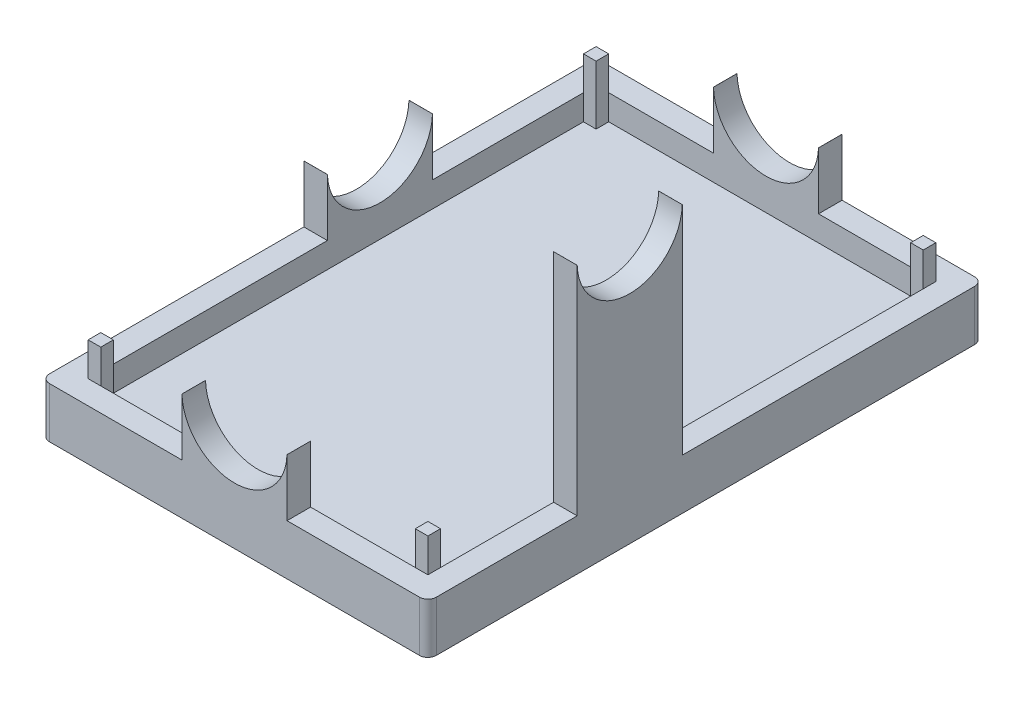
from build123d import *

# Parameters (mm, degrees)
SKETCH1_W           = 46
SKETCH1_H           = 66
BOSS_EXTRUDE1_DEPTH = 3
SKETCH2_W           = 46
SKETCH2_H           = 66
SKETCH2_W_2         = 40
SKETCH2_H_2         = 60
BOSS_EXTRUDE2_DEPTH = 3
SKETCH3_W           = 60
SKETCH3_H           = 3
CUT_EXTRUDE1_DEPTH  = 0.2
SKETCH4_W           = 40.2
SKETCH4_H           = 3
CUT_EXTRUDE2_DEPTH  = 0.2
SKETCH5_W           = 60.2
SKETCH5_H           = 3
CUT_EXTRUDE3_DEPTH  = 0.2
SKETCH6_W           = 40.4
SKETCH6_H           = 3
CUT_EXTRUDE4_DEPTH  = 0.2
BOSS_EXTRUDE3_DEPTH = 6.8
BOSS_EXTRUDE4_DEPTH = 6.8
SKETCH11_R          = 6.25
CUT_EXTRUDE5_DEPTH  = 66
BOSS_EXTRUDE5_DEPTH = 6.8
SKETCH13_R          = 6.25
CUT_EXTRUDE6_DEPTH  = 3
SKETCH14_W          = 2.8
SKETCH14_H          = 12.5
BOSS_EXTRUDE6_DEPTH = 25.8
SKETCH15_R          = 6.25
CUT_EXTRUDE7_DEPTH  = 4.8
SKETCH16_W          = 1.5
SKETCH16_H          = 1.5
BOSS_EXTRUDE7_DEPTH = 7
FILLET1_R           = 1
CUT_EXTRUDE8_DEPTH  = 0.2


with BuildPart() as part:
    # Sketch1 → Boss-Extrude1 (new body)
    with BuildSketch(Plane(origin=(0, 0, 0), x_dir=(1, 0, 0), z_dir=(0, 1, 0))):
        with Locations((27.944017639, 37.293489003)):
            Rectangle(SKETCH1_W, SKETCH1_H)
    extrude(amount=BOSS_EXTRUDE1_DEPTH)

    # Sketch2 → Boss-Extrude2 (add)
    with BuildSketch(Plane(origin=(0, 3, 0), x_dir=(1, 0, 0), z_dir=(0, 1, 0))):
        with Locations((27.944017639, 37.293489003)):
            Rectangle(SKETCH2_W, SKETCH2_H)
        with Locations((27.944017639, 37.293489003)):
            Rectangle(SKETCH2_W_2, SKETCH2_H_2, mode=Mode.SUBTRACT)
    extrude(amount=BOSS_EXTRUDE2_DEPTH)

    # Sketch3 → Cut-Extrude1 (cut)
    with BuildSketch(Plane(origin=(7.944017639, 0, 0), x_dir=(0, 0, -1), z_dir=(1, 0, 0))):
        with Locations((37.293489003, 4.5)):
            Rectangle(SKETCH3_W, SKETCH3_H)
    extrude(amount=-CUT_EXTRUDE1_DEPTH, mode=Mode.SUBTRACT)

    # Sketch4 → Cut-Extrude2 (cut)
    with BuildSketch(Plane(origin=(0, 0, -7.293489003), x_dir=(-1, 0, 0), z_dir=(0, 0, -1))):
        with Locations((-27.844017639, 4.5)):
            Rectangle(SKETCH4_W, SKETCH4_H)
    extrude(amount=-CUT_EXTRUDE2_DEPTH, mode=Mode.SUBTRACT)

    # Sketch5 → Cut-Extrude3 (cut)
    with BuildSketch(Plane.ZY.offset(-47.944017639)):
        with Locations((-37.193489003, 4.5)):
            Rectangle(SKETCH5_W, SKETCH5_H)
    extrude(amount=-CUT_EXTRUDE3_DEPTH, mode=Mode.SUBTRACT)

    # Sketch6 → Cut-Extrude4 (cut)
    with BuildSketch(Plane.XY.offset(-67.293489003)):
        with Locations((27.944017639, 4.5)):
            Rectangle(SKETCH6_W, SKETCH6_H)
    extrude(amount=-CUT_EXTRUDE4_DEPTH, mode=Mode.SUBTRACT)

    # Sketch8 → Boss-Extrude3 (add)
    with BuildSketch(Plane(origin=(0, 6, 0), x_dir=(1, 0, 0), z_dir=(0, 1, 0))):
        Polygon((27.944017639, 7.093489003), (34.194017639, 7.093489003), (34.194017639, 4.293489003), (21.694017639, 4.293489003), (21.694017639, 7.093489003), align=None)
    extrude(amount=BOSS_EXTRUDE3_DEPTH)

    # Sketch10 → Boss-Extrude4 (add)
    with BuildSketch(Plane(origin=(0, 6, 0), x_dir=(1, 0, 0), z_dir=(0, 1, 0))):
        Polygon((27.944017639, 67.493489003), (34.194017639, 67.493489003), (34.194017639, 70.293489003), (21.694017639, 70.293489003), (21.694017639, 67.493489003), align=None)
    extrude(amount=BOSS_EXTRUDE4_DEPTH)

    # Sketch11 → Cut-Extrude5 (cut)
    with BuildSketch(Plane.XY.offset(-4.293489003)):
        with Locations((27.944017639, 13)):
            Circle(SKETCH11_R)
    extrude(amount=-CUT_EXTRUDE5_DEPTH, mode=Mode.SUBTRACT)

    # Sketch12 → Boss-Extrude5 (add)
    with BuildSketch(Plane(origin=(0, 6, 0), x_dir=(1, 0, 0), z_dir=(0, 1, 0))):
        Polygon((7.744017639, 48.043489003), (4.944017639, 48.043489003), (4.944017639, 35.543489003), (7.744017639, 35.543489003), (7.744017639, 41.793489003), align=None)
    extrude(amount=BOSS_EXTRUDE5_DEPTH)

    # Sketch13 → Cut-Extrude6 (cut)
    with BuildSketch(Plane.ZY.offset(-4.944017639)):
        with Locations((-41.793489003, 13)):
            Circle(SKETCH13_R)
    extrude(amount=-CUT_EXTRUDE6_DEPTH, mode=Mode.SUBTRACT)

    # Sketch14 → Boss-Extrude6 (add)
    with BuildSketch(Plane(origin=(0, 6, 0), x_dir=(1, 0, 0), z_dir=(0, 1, 0))):
        with Locations((49.544017639, 28.293489003)):
            Rectangle(SKETCH14_W, SKETCH14_H)
    extrude(amount=BOSS_EXTRUDE6_DEPTH)

    # Sketch15 → Cut-Extrude7 (cut)
    with BuildSketch(Plane(origin=(50.944017639, 0, 0), x_dir=(0, 0, -1), z_dir=(1, 0, 0))):
        with Locations((28.293489003, 32)):
            Circle(SKETCH15_R)
    extrude(amount=-CUT_EXTRUDE7_DEPTH, mode=Mode.SUBTRACT)

    # Sketch16 → Boss-Extrude7 (add)
    with BuildSketch(Plane(origin=(0, 3, 0), x_dir=(1, 0, 0), z_dir=(0, 1, 0))):
        with Locations((8.494017639, 66.743489003)):
            Rectangle(SKETCH16_W, SKETCH16_H)
        with Locations((47.394017639, 66.743489003)):
            Rectangle(SKETCH16_W, SKETCH16_H)
        with Locations((47.394017639, 7.843489003)):
            Rectangle(SKETCH16_W, SKETCH16_H)
        with Locations((8.494017639, 7.843489003)):
            Rectangle(SKETCH16_W, SKETCH16_H)
    extrude(amount=BOSS_EXTRUDE7_DEPTH)

    # Fillet1
    fillet1_edges = [part.edges().sort_by_distance(p)[0] for p in [
        (4.944017639, 3, -4.293489003),
        (4.944017639, 3, -70.293489003),
        (50.944017639, 3, -70.293489003),
        (50.944017639, 3, -4.293489003),
    ]]
    fillet(fillet1_edges, radius=FILLET1_R)

    # Sketch17 → Cut-Extrude8 (cut)
    with BuildSketch(Plane.XZ):
        with BuildLine():
            Line((7.701195945, -7.422366579), (7.416260048, -7.422366579))
            add(Edge.make_bspline(
                [(7.416260048, -7.422366579), (7.419034677, -7.383077045), (7.424457453, -7.306289002), (7.442761371, -7.194981848), (7.466857748, -7.090008017), (7.500409578, -6.992544812), (7.540061397, -6.901315524), (7.589080984, -6.817817839), (7.644287116, -6.740222259), (7.707478986, -6.67028854), (7.776823348, -6.607925546), (7.851604145, -6.55348765), (7.931440576, -6.507658598), (8.01615079, -6.469639557), (8.106005461, -6.440672533), (8.200494018, -6.419499916), (8.300015054, -6.40747827), (8.367922694, -6.405666733), (8.402723389, -6.404738373)],
                knots=[0, 0, 0, 0, 0.000118102, 0.000230821, 0.000338037, 0.000440814, 0.000539618, 0.000635943, 0.000730729, 0.000824853, 0.000918079, 0.001010058, 0.001101805, 0.001193764, 0.001288095, 0.001384537, 0.001483857, 0.001588259, 0.001588259, 0.001588259, 0.001588259], degree=3))
            add(Edge.make_bspline(
                [(8.402723389, -6.404738373), (8.432217299, -6.405535017), (8.490345422, -6.407105084), (8.575705535, -6.417598326), (8.65705849, -6.437289), (8.73492156, -6.462835101), (8.808495833, -6.49731523), (8.879130104, -6.537777123), (8.945117015, -6.587311256), (9.007253139, -6.642883778), (9.063436321, -6.704093768), (9.112539208, -6.769437735), (9.155461258, -6.83764641), (9.188583072, -6.910708574), (9.215971134, -6.986455297), (9.233919047, -7.066179452), (9.245967298, -7.149146601), (9.247308133, -7.205863872), (9.247990817, -7.234741378)],
                knots=[0, 0, 0, 0, 8.8489e-05, 0.000174398, 0.000257396, 0.000339254, 0.00041979, 0.000500732, 0.000583034, 0.000666805, 0.000750533, 0.000831816, 0.000911775, 0.000991734, 0.001071996, 0.00115299, 0.001236461, 0.001323044, 0.001323044, 0.001323044, 0.001323044], degree=3))
            add(Edge.make_bspline(
                [(9.247990817, -7.234741378), (9.246566417, -7.275772035), (9.243701708, -7.358291646), (9.218768832, -7.481267417), (9.179708866, -7.603516288), (9.133872645, -7.705762826), (9.083725636, -7.791758647), (9.033319874, -7.86708166), (8.970049243, -7.952207882), (8.893758432, -8.04698303), (8.805433211, -8.152455781), (8.704315944, -8.268051488), (8.590222285, -8.39336902), (8.509273292, -8.479542277), (8.46696117, -8.524585128)],
                knots=[0, 0, 0, 0, 0.000122988, 0.000247351, 0.000374875, 0.000507521, 0.000582466, 0.000673312, 0.000779275, 0.000900556, 0.001038261, 0.001191968, 0.001361261, 0.001546658, 0.001546658, 0.001546658, 0.001546658], degree=3))
            Line((8.46696117, -8.524585128), (7.684023469, -9.376212732))
            Line((7.684023469, -9.376212732), (9.085170304, -9.376212732))
            Line((9.085170304, -9.376212732), (9.0489173, -9.66114863))
            Line((9.0489173, -9.66114863), (7.049913894, -9.66114863))
            Line((7.049913894, -9.66114863), (8.113971386, -8.504232564))
            add(Edge.make_bspline(
                [(8.113971386, -8.504232564), (8.138795432, -8.477113353), (8.187230161, -8.424200478), (8.257739029, -8.346526365), (8.324839919, -8.27300936), (8.386896429, -8.202001127), (8.446115539, -8.135468803), (8.501599693, -8.072420652), (8.552987828, -8.012911133), (8.600239669, -7.956524636), (8.643936381, -7.903967516), (8.68411955, -7.85524987), (8.719803985, -7.809593952), (8.752276538, -7.768168395), (8.780282375, -7.729489812), (8.805212384, -7.695084219), (8.825432982, -7.663533689), (8.858533166, -7.611717812), (8.896348205, -7.535227), (8.934983702, -7.433625775), (8.958210789, -7.332456636), (8.961461954, -7.26516704), (8.96305492, -7.232197308)],
                knots=[0, 0, 0, 0, 0.000110295, 0.0002152, 0.000314714, 0.000408889, 0.0004981, 0.000581924, 0.000660844, 0.000733972, 0.000802621, 0.000865897, 0.00092341, 0.00097646, 0.001023782, 0.001066665, 0.001103887, 0.00113618, 0.001251095, 0.00135896, 0.001461887, 0.001560765, 0.001560765, 0.001560765, 0.001560765], degree=3))
            add(Edge.make_bspline(
                [(8.96305492, -7.232197308), (8.962575453, -7.213516243), (8.961634143, -7.176840793), (8.953913828, -7.122841286), (8.940498496, -7.071286866), (8.92188294, -7.021849715), (8.898143989, -6.974591647), (8.869577616, -6.929101673), (8.834905225, -6.88650684), (8.795544901, -6.846662619), (8.75255776, -6.81009226), (8.706872832, -6.777051851), (8.657329765, -6.75068476), (8.605798295, -6.728045693), (8.551125902, -6.711049698), (8.493991951, -6.698027352), (8.433626184, -6.691273998), (8.392561426, -6.690215598), (8.371558526, -6.689674271)],
                knots=[0, 0, 0, 0, 5.6027e-05, 0.000109995, 0.000163216, 0.000215547, 0.000268168, 0.000321631, 0.000376362, 0.00043258, 0.000489425, 0.000545542, 0.000601327, 0.000657449, 0.000714172, 0.00077281, 0.000833003, 0.000896021, 0.000896021, 0.000896021, 0.000896021], degree=3))
            add(Edge.make_bspline(
                [(8.371558526, -6.689674271), (8.348206108, -6.690290482), (8.30259887, -6.691493942), (8.235767363, -6.700773218), (8.171948622, -6.715101293), (8.111096175, -6.736148384), (8.053888929, -6.763891968), (7.999159077, -6.79627855), (7.948065765, -6.835467475), (7.900618921, -6.880509602), (7.857111509, -6.93084104), (7.819034171, -6.986453828), (7.785534245, -7.046813598), (7.757728935, -7.112274814), (7.735488391, -7.182835695), (7.718503545, -7.258154393), (7.706083985, -7.33847721), (7.702853868, -7.393913031), (7.701195945, -7.422366579)],
                knots=[0, 0, 0, 0, 7.0034e-05, 0.000136777, 0.000202039, 0.000266002, 0.000329442, 0.000392488, 0.000456473, 0.000522159, 0.000588454, 0.000655671, 0.000723994, 0.000795231, 0.000868649, 0.000945639, 0.001026683, 0.001112147, 0.001112147, 0.001112147, 0.001112147], degree=3))
        make_face()
        Polygon((10.140959567, -6.48614863), (10.427803518, -6.48614863), (10.245266458, -7.788712732), (11.910360609, -7.788712732), (12.092897668, -6.48614863), (12.379741619, -6.48614863), (11.934529279, -9.66114863), (11.647685328, -9.66114863), (11.870291498, -8.07364863), (10.205197348, -8.07364863), (9.982591178, -9.66114863), (9.695747228, -9.66114863), align=None)
        Polygon((13.969785689, -6.48614863), (15.842221586, -6.48614863), (15.801516458, -6.771084527), (15.025574952, -6.771084527), (14.622975793, -9.66114863), (14.336131843, -9.66114863), (14.738731002, -6.771084527), (13.929080561, -6.771084527), align=None)
        Polygon((17.511131843, -6.404738373), (16.143057925, -10.10890504), (15.842221586, -10.10890504), (17.210295505, -6.404738373), align=None)
        with BuildLine():
            Line((18.24128008, -6.48614863), (19.027397869, -6.48614863))
            add(Edge.make_bspline(
                [(19.027397869, -6.48614863), (19.061112566, -6.4863509), (19.126232793, -6.486741586), (19.219947055, -6.490879428), (19.306371647, -6.495949194), (19.384998478, -6.505260745), (19.456705596, -6.515433351), (19.520533841, -6.529549014), (19.577230613, -6.545157131), (19.642209667, -6.56966321), (19.715313779, -6.60784007), (19.793896134, -6.665914392), (19.863669529, -6.735893476), (19.923749499, -6.816769877), (19.973964699, -6.906364305), (20.009494771, -7.004490092), (20.0311297, -7.109773411), (20.033588082, -7.182269809), (20.034849792, -7.219476955)],
                knots=[0, 0, 0, 0, 0.000101135, 0.000195343, 0.000281396, 0.000360763, 0.000432813, 0.000498557, 0.000556741, 0.000609073, 0.000706649, 0.000803072, 0.000901114, 0.001001987, 0.001104472, 0.001208096, 0.00131387, 0.001425393, 0.001425393, 0.001425393, 0.001425393], degree=3))
            add(Edge.make_bspline(
                [(20.034849792, -7.219476955), (20.033413752, -7.260544968), (20.030563738, -7.342049996), (20.002931273, -7.461462371), (19.960239208, -7.576566351), (19.900338278, -7.685354314), (19.826516808, -7.78567787), (19.738820416, -7.873879323), (19.638853413, -7.949190663), (19.545060683, -7.998890583), (19.464274136, -8.033086626), (19.397803593, -8.053983449), (19.327416681, -8.073760096), (19.251724022, -8.087584111), (19.171853488, -8.100129923), (19.087092858, -8.107938549), (18.997995963, -8.113206933), (18.937091721, -8.113965495), (18.905918502, -8.114353758)],
                knots=[0, 0, 0, 0, 0.00012303, 0.000244169, 0.00036573, 0.000490396, 0.000615439, 0.000738217, 0.00086224, 0.000989445, 0.001055591, 0.001125182, 0.001198313, 0.001274776, 0.00135582, 0.001440813, 0.001530001, 0.001623515, 0.001623515, 0.001623515, 0.001623515], degree=3))
            Line((18.905918502, -8.114353758), (19.912734407, -9.66114863))
            Line((19.912734407, -9.66114863), (19.587093381, -9.66114863))
            Line((19.587093381, -9.66114863), (18.580277476, -8.114353758))
            Line((18.580277476, -8.114353758), (18.299793702, -8.114353758))
            Line((18.299793702, -8.114353758), (18.082911691, -9.66114863))
            Line((18.082911691, -9.66114863), (17.79606774, -9.66114863))
            Line((17.79606774, -9.66114863), (18.24128008, -6.48614863))
        make_face()
        with BuildLine():
            Line((18.48805492, -6.771084527), (18.339862812, -7.829417861))
            Line((18.339862812, -7.829417861), (18.717657284, -7.829417861))
            add(Edge.make_bspline(
                [(18.717657284, -7.829417861), (18.751154509, -7.829245458), (18.815183183, -7.828915916), (18.906568812, -7.82782596), (18.988851324, -7.82542151), (19.061979555, -7.821409674), (19.126292158, -7.817392704), (19.181387987, -7.811468066), (19.227593654, -7.805761374), (19.254911516, -7.799701628), (19.267176514, -7.796980962)],
                knots=[0, 0, 0, 0, 0.000100493, 0.000192088, 0.000274174, 0.000347415, 0.000411807, 0.000467436, 0.000513669, 0.000551339, 0.000551339, 0.000551339, 0.000551339], degree=3))
            add(Edge.make_bspline(
                [(19.267176514, -7.796980962), (19.301927816, -7.787507292), (19.369956218, -7.768961841), (19.463231092, -7.722590757), (19.547116979, -7.665603761), (19.607130755, -7.606975865), (19.648630163, -7.554795696), (19.675396259, -7.513099296), (19.698550034, -7.469560574), (19.71763058, -7.423825703), (19.732359229, -7.37589718), (19.742328097, -7.325804315), (19.749034283, -7.273720736), (19.749617853, -7.238155142), (19.749913894, -7.220112973)],
                knots=[0, 0, 0, 0, 0.000107831, 0.000211087, 0.000310766, 0.000411065, 0.000461326, 0.000510547, 0.000559483, 0.000609093, 0.000658987, 0.000709629, 0.000762169, 0.000816264, 0.000816264, 0.000816264, 0.000816264], degree=3))
            add(Edge.make_bspline(
                [(19.749913894, -7.220112973), (19.749213027, -7.200161671), (19.747849846, -7.161356502), (19.739908979, -7.105081757), (19.725137899, -7.053187928), (19.704791958, -7.005596599), (19.678280962, -6.962450712), (19.646334464, -6.923372885), (19.608338828, -6.888528133), (19.579526225, -6.869297801), (19.564832764, -6.859490978)],
                knots=[0, 0, 0, 0, 5.987e-05, 0.000116447, 0.000170001, 0.000221279, 0.000271237, 0.000321402, 0.000372272, 0.00042521, 0.00042521, 0.00042521, 0.00042521], degree=3))
            add(Edge.make_bspline(
                [(19.564832764, -6.859490978), (19.551858137, -6.852136558), (19.524440206, -6.836595227), (19.477271572, -6.819530035), (19.423800206, -6.80408803), (19.362868124, -6.792401612), (19.294931083, -6.782980358), (19.219794005, -6.776205919), (19.137699395, -6.771553924), (19.080618539, -6.771245132), (19.050930521, -6.771084527)],
                knots=[0, 0, 0, 0, 4.4671e-05, 9.4398e-05, 0.000149962, 0.00021158, 0.000280299, 0.000355675, 0.000437842, 0.000526893, 0.000526893, 0.000526893, 0.000526893], degree=3))
            Line((19.050930521, -6.771084527), (18.48805492, -6.771084527))
        make_face(mode=Mode.SUBTRACT)
        with BuildLine():
            Line((23.535490817, -7.103085729), (23.23719855, -7.178135809))
            add(Edge.make_bspline(
                [(23.23719855, -7.178135809), (23.225673366, -7.142131514), (23.20326407, -7.072125614), (23.154186815, -6.976175074), (23.095590465, -6.891312755), (23.025923088, -6.820688273), (22.951329698, -6.762356021), (22.871376551, -6.720767149), (22.788332041, -6.694442005), (22.731326321, -6.691259038), (22.702943742, -6.689674271)],
                knots=[0, 0, 0, 0, 0.000113249, 0.000220198, 0.00032201, 0.000421411, 0.00051669, 0.000604877, 0.000690591, 0.000775584, 0.000775584, 0.000775584, 0.000775584], degree=3))
            add(Edge.make_bspline(
                [(22.702943742, -6.689674271), (22.672470475, -6.69100545), (22.613761392, -6.693570069), (22.5299708, -6.717207117), (22.455650296, -6.756778381), (22.39095532, -6.810532082), (22.338148867, -6.877316304), (22.300256495, -6.955860371), (22.277676273, -7.044816475), (22.27501628, -7.10740141), (22.273631843, -7.139974752)],
                knots=[0, 0, 0, 0, 9.127e-05, 0.000175839, 0.000258634, 0.000342185, 0.000426418, 0.000512038, 0.00060197, 0.00069958, 0.00069958, 0.00069958, 0.00069958], degree=3))
            add(Edge.make_bspline(
                [(22.273631843, -7.139974752), (22.275034391, -7.170671796), (22.277901268, -7.233418058), (22.304514579, -7.327377916), (22.343619272, -7.423709805), (22.380837046, -7.485162723), (22.400199351, -7.517133205)],
                knots=[0, 0, 0, 0, 9.1904e-05, 0.000187856, 0.000291087, 0.00040303, 0.00040303, 0.00040303, 0.00040303], degree=3))
            add(Edge.make_bspline(
                [(22.400199351, -7.517133205), (22.407678521, -7.528269502), (22.424077993, -7.552687906), (22.454284492, -7.589706532), (22.49074716, -7.631508118), (22.534824664, -7.676770433), (22.585083769, -7.727226333), (22.642257748, -7.781820985), (22.70672706, -7.84031762), (22.752283494, -7.880364305), (22.776085769, -7.901287853)],
                knots=[0, 0, 0, 0, 4.0225e-05, 8.8201e-05, 0.000143187, 0.000206613, 0.000277671, 0.000356844, 0.000443737, 0.00053881, 0.00053881, 0.00053881, 0.00053881], degree=3))
            add(Edge.make_bspline(
                [(22.776085769, -7.901287853), (22.800946296, -7.92305821), (22.849398492, -7.965487785), (22.91936201, -8.028674719), (22.981794072, -8.092299589), (23.038993718, -8.154342404), (23.090205641, -8.214973786), (23.136146657, -8.274485016), (23.17515032, -8.333441931), (23.219901366, -8.408764475), (23.263583731, -8.502723949), (23.303416312, -8.615135313), (23.32727946, -8.72710632), (23.330421907, -8.80157161), (23.331965176, -8.838141819)],
                knots=[0, 0, 0, 0, 9.9141e-05, 0.000193222, 0.00028272, 0.000366448, 0.000446336, 0.000520753, 0.000591842, 0.000658271, 0.000783455, 0.000901927, 0.001015561, 0.001125222, 0.001125222, 0.001125222, 0.001125222], degree=3))
            add(Edge.make_bspline(
                [(23.331965176, -8.838141819), (23.330278343, -8.87641787), (23.326910487, -8.952838119), (23.302501199, -9.0662297), (23.261800633, -9.177048183), (23.206041236, -9.284187638), (23.137403787, -9.385078432), (23.055707507, -9.475334064), (22.963489915, -9.555025606), (22.860922613, -9.621975999), (22.751243436, -9.674922384), (22.637527196, -9.714733779), (22.519880817, -9.738108337), (22.440156375, -9.74107302), (22.400199351, -9.742558886)],
                knots=[0, 0, 0, 0, 0.000114781, 0.000229167, 0.000346267, 0.000468018, 0.000590626, 0.000711318, 0.000832182, 0.000955313, 0.001077629, 0.001196702, 0.001315948, 0.001435762, 0.001435762, 0.001435762, 0.001435762], degree=3))
            add(Edge.make_bspline(
                [(22.400199351, -9.742558886), (22.374939936, -9.7419344), (22.32511162, -9.7407025), (22.2515681, -9.731312129), (22.180176565, -9.717424609), (22.112038194, -9.694970869), (22.045919729, -9.668638811), (21.982931051, -9.635132113), (21.922065048, -9.596298255), (21.864339234, -9.550953082), (21.809466109, -9.500264906), (21.759090082, -9.443142993), (21.712759502, -9.380650713), (21.669755849, -9.312768586), (21.631175347, -9.239119702), (21.597029456, -9.159877758), (21.566018282, -9.075469923), (21.549445101, -9.016564785), (21.540939535, -8.986333926)],
                knots=[0, 0, 0, 0, 7.5753e-05, 0.000149435, 0.000222155, 0.000293562, 0.000364309, 0.000435432, 0.000507238, 0.000580647, 0.000655352, 0.00073104, 0.000808762, 0.000888518, 0.000971876, 0.001057896, 0.001147228, 0.00124141, 0.00124141, 0.00124141, 0.00124141], degree=3))
            Line((21.540939535, -8.986333926), (21.832871627, -8.887751194))
            add(Edge.make_bspline(
                [(21.832871627, -8.887751194), (21.839138068, -8.911163549), (21.851387212, -8.956928172), (21.874410039, -9.022272969), (21.899906314, -9.083010769), (21.927777638, -9.139332427), (21.959012515, -9.191056411), (21.993234447, -9.238128568), (22.030394027, -9.280384219), (22.069937142, -9.318114966), (22.111704439, -9.351097335), (22.155555705, -9.379258406), (22.200693695, -9.403681656), (22.247833633, -9.423286803), (22.296345631, -9.438735905), (22.346433049, -9.449307657), (22.397848369, -9.456893618), (22.432819905, -9.457378579), (22.450444744, -9.457622989)],
                knots=[0, 0, 0, 0, 7.2687e-05, 0.000142083, 0.000207642, 0.000270218, 0.000330428, 0.000388693, 0.000444575, 0.00049901, 0.00055245, 0.000603964, 0.000655182, 0.00070621, 0.000756901, 0.000807675, 0.000859665, 0.000912489, 0.000912489, 0.000912489, 0.000912489], degree=3))
            add(Edge.make_bspline(
                [(22.450444744, -9.457622989), (22.470406941, -9.457210987), (22.509872794, -9.456396446), (22.567947626, -9.447586229), (22.62414671, -9.434656718), (22.677871477, -9.415098937), (22.729814837, -9.390984724), (22.779340166, -9.360929306), (22.826868967, -9.325626778), (22.87142418, -9.285227281), (22.912619611, -9.241225887), (22.948599031, -9.193663476), (22.979016261, -9.143560985), (23.004200991, -9.091008095), (23.023159981, -9.035865208), (23.037297511, -8.978439306), (23.045758016, -8.918321192), (23.046600885, -8.877389938), (23.047029279, -8.85658633)],
                knots=[0, 0, 0, 0, 5.984e-05, 0.000118305, 0.000175846, 0.000232577, 0.000289482, 0.000347401, 0.000406042, 0.000466838, 0.000527593, 0.000586616, 0.000645409, 0.000703161, 0.000761091, 0.000820018, 0.000880373, 0.000942754, 0.000942754, 0.000942754, 0.000942754], degree=3))
            add(Edge.make_bspline(
                [(23.047029279, -8.85658633), (23.045735475, -8.825550786), (23.043143014, -8.763363258), (23.024157789, -8.670755986), (22.9916928, -8.580008906), (22.954893375, -8.505528009), (22.918284974, -8.445122973), (22.883582626, -8.397663691), (22.843264029, -8.34777534), (22.796822605, -8.295943472), (22.744608206, -8.24164817), (22.685731291, -8.186007968), (22.621720616, -8.127171674), (22.575890972, -8.088529582), (22.552207564, -8.068560489)],
                knots=[0, 0, 0, 0, 9.3076e-05, 0.000186501, 0.000282251, 0.000381521, 0.000435188, 0.000493967, 0.000557737, 0.000627563, 0.000702681, 0.000783653, 0.000870545, 0.000963469, 0.000963469, 0.000963469, 0.000963469], degree=3))
            add(Edge.make_bspline(
                [(22.552207564, -8.068560489), (22.52705614, -8.04708803), (22.478615992, -8.005733349), (22.41099816, -7.943723691), (22.348949187, -7.886856401), (22.294505558, -7.83335422), (22.246175005, -7.784500672), (22.205803688, -7.738761685), (22.171506708, -7.697419222), (22.152222645, -7.670309447), (22.143248229, -7.657693101)],
                knots=[0, 0, 0, 0, 9.9202e-05, 0.000191058, 0.000275217, 0.000351677, 0.000420042, 0.000481311, 0.000534653, 0.000581087, 0.000581087, 0.000581087, 0.000581087], degree=3))
            add(Edge.make_bspline(
                [(22.143248229, -7.657693101), (22.130825338, -7.637956761), (22.106222474, -7.598870005), (22.07567921, -7.537620639), (22.048240655, -7.476381374), (22.026972665, -7.413867365), (22.009378679, -7.35068458), (21.997492644, -7.286621475), (21.990282632, -7.221762394), (21.989227385, -7.178366232), (21.988695945, -7.15651121)],
                knots=[0, 0, 0, 0, 6.9919e-05, 0.00013847, 0.000205115, 0.00027109, 0.000336355, 0.00040172, 0.000466337, 0.000531897, 0.000531897, 0.000531897, 0.000531897], degree=3))
            add(Edge.make_bspline(
                [(21.988695945, -7.15651121), (21.989239326, -7.129977111), (21.990308547, -7.077765384), (22.000772016, -7.001072067), (22.017818371, -6.928023447), (22.041503915, -6.85847426), (22.072215099, -6.79258687), (22.10990011, -6.730251512), (22.153953236, -6.671192318), (22.2050031, -6.616968349), (22.260229802, -6.566980901), (22.319664324, -6.52343732), (22.382460967, -6.487019448), (22.448294378, -6.457042736), (22.517410592, -6.433092514), (22.590007801, -6.417093722), (22.665728802, -6.406252082), (22.717320442, -6.405249841), (22.74364887, -6.404738373)],
                knots=[0, 0, 0, 0, 7.9566e-05, 0.000156563, 0.000231694, 0.000304303, 0.000376577, 0.000449331, 0.000522473, 0.000597178, 0.000672392, 0.000745667, 0.000817773, 0.00088978, 0.00096239, 0.001036757, 0.001112494, 0.001191424, 0.001191424, 0.001191424, 0.001191424], degree=3))
            add(Edge.make_bspline(
                [(22.74364887, -6.404738373), (22.765934563, -6.405173223), (22.810028516, -6.406033607), (22.875193513, -6.414533161), (22.93831533, -6.428672302), (22.999728901, -6.447667812), (23.059167209, -6.47257608), (23.116495579, -6.503591473), (23.172682664, -6.538858448), (23.225983653, -6.580577301), (23.277202943, -6.6269733), (23.324803557, -6.67921262), (23.368915716, -6.736961289), (23.409588538, -6.799882829), (23.446349825, -6.868342562), (23.480163351, -6.941518889), (23.510174105, -7.020198759), (23.526910542, -7.07499389), (23.535490817, -7.103085729)],
                knots=[0, 0, 0, 0, 6.683e-05, 0.000132229, 0.000196731, 0.0002607, 0.00032484, 0.000389714, 0.000456055, 0.000523608, 0.000592489, 0.000663167, 0.000735296, 0.000810273, 0.000887682, 0.000968218, 0.001051965, 0.001140066, 0.001140066, 0.001140066, 0.001140066], degree=3))
        make_face()
        Polygon((23.861131843, -7.340956322), (24.154335969, -7.340956322), (24.593824151, -8.96916145), (25.468348389, -7.340956322), (25.509689535, -7.340956322), (26.059208766, -8.989514015), (26.914016458, -7.340956322), (27.229481202, -7.340956322), (26.022319744, -9.66114863), (25.981614615, -9.66114863), (25.428279279, -8.005594744), (24.539126635, -9.66114863), (24.487609207, -9.66114863), align=None)
        with BuildLine():
            add(Edge.make_bspline(
                [(27.931644663, -6.364033245), (27.947844696, -6.364870677), (27.979760562, -6.366520511), (28.025924245, -6.380235375), (28.067713176, -6.403852785), (28.105082684, -6.434825994), (28.136055893, -6.472195502), (28.159673303, -6.513984433), (28.173388167, -6.560148116), (28.175038001, -6.592063982), (28.175875433, -6.608264015)],
                knots=[0, 0, 0, 0, 4.8542e-05, 9.5633e-05, 0.000142891, 0.00019167, 0.000240449, 0.000287707, 0.000334798, 0.00038334, 0.00038334, 0.00038334, 0.00038334], degree=3))
            add(Edge.make_bspline(
                [(28.175875433, -6.608264015), (28.175030639, -6.624671875), (28.173366373, -6.656995785), (28.159816766, -6.703643068), (28.136057714, -6.745628249), (28.105029212, -6.782869658), (28.068076426, -6.814203709), (28.025543016, -6.836005026), (27.979809029, -6.850097351), (27.947861014, -6.851687598), (27.931644663, -6.852494784)],
                knots=[0, 0, 0, 0, 4.9175e-05, 9.6877e-05, 0.000144135, 0.000192914, 0.000241693, 0.000288348, 0.000335439, 0.000383981, 0.000383981, 0.000383981, 0.000383981], degree=3))
            add(Edge.make_bspline(
                [(27.931644663, -6.852494784), (27.915220173, -6.851680802), (27.882863502, -6.850077238), (27.836649709, -6.836142732), (27.793917919, -6.814204756), (27.7570923, -6.782816378), (27.725703921, -6.745990758), (27.703765946, -6.703258969), (27.68983144, -6.657045176), (27.688227876, -6.624688505), (27.687413894, -6.608264015)],
                knots=[0, 0, 0, 0, 4.9175e-05, 9.6877e-05, 0.000143532, 0.000192311, 0.00024109, 0.000287745, 0.000335446, 0.000384622, 0.000384622, 0.000384622, 0.000384622], degree=3))
            add(Edge.make_bspline(
                [(27.687413894, -6.608264015), (27.68822108, -6.592047664), (27.689811326, -6.560099649), (27.703903652, -6.514365662), (27.725704969, -6.471832252), (27.75703902, -6.434879466), (27.794280429, -6.403850964), (27.83626561, -6.380091912), (27.882912893, -6.366542305), (27.915236803, -6.364878039), (27.931644663, -6.364033245)],
                knots=[0, 0, 0, 0, 4.8542e-05, 9.5633e-05, 0.000142288, 0.000191067, 0.000239846, 0.000287104, 0.000334806, 0.000383981, 0.000383981, 0.000383981, 0.000383981], degree=3))
        make_face()
        Polygon((27.69123, -7.340956322), (27.97807395, -7.340956322), (27.648616819, -9.66114863), (27.361772869, -9.66114863), align=None)
        Polygon((29.076476394, -6.404738373), (29.363320344, -6.404738373), (29.232936731, -7.340956322), (29.722670304, -7.340956322), (29.688325353, -7.62589222), (29.193503638, -7.62589222), (28.910475793, -9.66114863), (28.623631843, -9.66114863), (28.906659687, -7.62589222), (28.46081133, -7.62589222), (28.497700353, -7.340956322), (28.94609278, -7.340956322), align=None)
        with BuildLine():
            Line((32.368503638, -7.84849839), (32.121728798, -7.992238373))
            add(Edge.make_bspline(
                [(32.121728798, -7.992238373), (32.099465714, -7.95977881), (32.055714544, -7.895989629), (31.976347881, -7.812754441), (31.888727956, -7.74241034), (31.792716182, -7.684103397), (31.687624577, -7.639719948), (31.573949445, -7.607947075), (31.451815952, -7.588584365), (31.36748467, -7.586340032), (31.324162692, -7.585187091)],
                knots=[0, 0, 0, 0, 0.000117931, 0.000231757, 0.000343503, 0.000454215, 0.000567626, 0.000684607, 0.000807576, 0.000937479, 0.000937479, 0.000937479, 0.000937479], degree=3))
            add(Edge.make_bspline(
                [(31.324162692, -7.585187091), (31.273395308, -7.586742797), (31.173357149, -7.589808346), (31.026700604, -7.615089979), (30.887234405, -7.657481912), (30.776877756, -7.705609857), (30.693919454, -7.752137794), (30.635152687, -7.79050983), (30.579692463, -7.831918073), (30.527499144, -7.876378511), (30.478745627, -7.924175687), (30.43458659, -7.975983565), (30.392719156, -8.03023881), (30.342570342, -8.106519131), (30.290293792, -8.206821902), (30.244680171, -8.332716458), (30.216019822, -8.462875713), (30.212766278, -8.551365695), (30.211131843, -8.595819103)],
                knots=[0, 0, 0, 0, 0.000152233, 0.000299978, 0.000444845, 0.000588661, 0.000660136, 0.000729994, 0.000799065, 0.000867637, 0.000935548, 0.001003638, 0.001071695, 0.001141021, 0.001277284, 0.001409871, 0.001541847, 0.001675073, 0.001675073, 0.001675073, 0.001675073], degree=3))
            add(Edge.make_bspline(
                [(30.211131843, -8.595819103), (30.212168742, -8.634718835), (30.214201023, -8.710960729), (30.235668082, -8.821969834), (30.268385127, -8.927142007), (30.314910486, -9.025164266), (30.373424492, -9.114534414), (30.443198471, -9.193481751), (30.524128435, -9.261207629), (30.615268651, -9.31784469), (30.716358342, -9.362422624), (30.826282593, -9.39415687), (30.944833005, -9.413566329), (31.026853966, -9.415778118), (31.069119623, -9.416917861)],
                knots=[0, 0, 0, 0, 0.000116565, 0.000228462, 0.000337887, 0.000446281, 0.000552829, 0.000657356, 0.000761185, 0.000868312, 0.000978224, 0.001091536, 0.001210737, 0.001337464, 0.001337464, 0.001337464, 0.001337464], degree=3))
            add(Edge.make_bspline(
                [(31.069119623, -9.416917861), (31.113283966, -9.4157052), (31.200968879, -9.413297555), (31.331034244, -9.393631175), (31.457696471, -9.361076877), (31.579606249, -9.316704065), (31.69355192, -9.263258354), (31.795520902, -9.200324055), (31.885294126, -9.13112652), (31.934797329, -9.076955946), (31.958908285, -9.050571707)],
                knots=[0, 0, 0, 0, 0.000132444, 0.000262958, 0.000393616, 0.000524192, 0.000651645, 0.000770437, 0.000883178, 0.000990229, 0.000990229, 0.000990229, 0.000990229], degree=3))
            Line((31.958908285, -9.050571707), (32.205683125, -9.224204519))
            add(Edge.make_bspline(
                [(32.205683125, -9.224204519), (32.167407451, -9.263559407), (32.092659508, -9.340414927), (31.970371386, -9.440505581), (31.842405016, -9.522745131), (31.709332108, -9.59030706), (31.567845588, -9.641018831), (31.416729489, -9.676095928), (31.255072953, -9.698331512), (31.143609373, -9.700657618), (31.086292099, -9.701853758)],
                knots=[0, 0, 0, 0, 0.000164605, 0.000321453, 0.000472822, 0.00062016, 0.000768233, 0.000922501, 0.00108486, 0.001256727, 0.001256727, 0.001256727, 0.001256727], degree=3))
            add(Edge.make_bspline(
                [(31.086292099, -9.701853758), (31.041939484, -9.701118383), (30.955544509, -9.699685937), (30.829691409, -9.685101567), (30.711177843, -9.662936984), (30.60034316, -9.630087687), (30.4968703, -9.588933204), (30.400640592, -9.538332783), (30.311737037, -9.478626005), (30.231660986, -9.408816014), (30.159865369, -9.332048171), (30.096990209, -9.248812911), (30.043739345, -9.15936845), (30.00125454, -9.063043647), (29.967444602, -8.961060014), (29.943167568, -8.85287518), (29.92932509, -8.738647617), (29.927253652, -8.660517938), (29.926195945, -8.62062379)],
                knots=[0, 0, 0, 0, 0.000133002, 0.000259077, 0.000379571, 0.000494284, 0.000605303, 0.000713128, 0.000819852, 0.000925816, 0.001031115, 0.001134658, 0.001238173, 0.00134266, 0.001449861, 0.001560031, 0.001674735, 0.001794415, 0.001794415, 0.001794415, 0.001794415], degree=3))
            add(Edge.make_bspline(
                [(29.926195945, -8.62062379), (29.927366456, -8.575819571), (29.92966857, -8.487700371), (29.949444434, -8.358105646), (29.981250902, -8.233418488), (30.025696605, -8.113411045), (30.083825989, -7.998927996), (30.153215747, -7.888716741), (30.236638852, -7.784268313), (30.331504865, -7.685835689), (30.43516194, -7.595688282), (30.546171559, -7.51669167), (30.66272556, -7.449912934), (30.78494966, -7.394374392), (30.913393248, -7.352970207), (31.047107643, -7.321852479), (31.186733207, -7.304165035), (31.281714036, -7.301568246), (31.329886851, -7.300251194)],
                knots=[0, 0, 0, 0, 0.00013435, 0.000264235, 0.000392271, 0.000519862, 0.000647289, 0.000776801, 0.000909904, 0.001047548, 0.001186419, 0.001321425, 0.001455614, 0.00158884, 0.001723395, 0.001859783, 0.002000205, 0.002144721, 0.002144721, 0.002144721, 0.002144721], degree=3))
            add(Edge.make_bspline(
                [(31.329886851, -7.300251194), (31.358940106, -7.300846843), (31.416265909, -7.302022134), (31.501055473, -7.308130838), (31.583206934, -7.319755786), (31.662866131, -7.335589232), (31.739793205, -7.355873499), (31.814243169, -7.380751397), (31.885651011, -7.410733938), (31.954726174, -7.444263529), (32.019896307, -7.482564159), (32.081978699, -7.523830299), (32.139741053, -7.568973933), (32.193827176, -7.617774006), (32.243536568, -7.670286042), (32.289904549, -7.725828715), (32.331388462, -7.78545858), (32.356049466, -7.827345085), (32.368503638, -7.84849839)],
                knots=[0, 0, 0, 0, 8.7172e-05, 0.000172001, 0.000254842, 0.000335918, 0.000415522, 0.000493359, 0.000571197, 0.000647713, 0.000723527, 0.000797791, 0.000871201, 0.000943248, 0.001016127, 0.001087952, 0.001160117, 0.001233744, 0.001233744, 0.001233744, 0.001233744], degree=3))
        make_face()
        with BuildLine():
            Line((33.191510449, -6.404738373), (33.478354399, -6.404738373))
            Line((33.478354399, -6.404738373), (33.29581734, -7.705394423))
            add(Edge.make_bspline(
                [(33.29581734, -7.705394423), (33.325808178, -7.673267328), (33.384418823, -7.61048183), (33.479373164, -7.527483783), (33.578133155, -7.457532984), (33.6797946, -7.399863697), (33.785352836, -7.355570614), (33.894068488, -7.323555099), (34.00638507, -7.303887016), (34.082493536, -7.301467044), (34.120732203, -7.300251194)],
                knots=[0, 0, 0, 0, 0.000131791, 0.000257557, 0.000377555, 0.000494313, 0.000607475, 0.000720178, 0.000833732, 0.000948391, 0.000948391, 0.000948391, 0.000948391], degree=3))
            add(Edge.make_bspline(
                [(34.120732203, -7.300251194), (34.149812126, -7.300764935), (34.206675848, -7.301769518), (34.289821333, -7.312477121), (34.369137787, -7.328629711), (34.444239203, -7.352357393), (34.51543924, -7.382091581), (34.581859645, -7.419506889), (34.644705808, -7.462877364), (34.70274975, -7.512911535), (34.755441544, -7.568021127), (34.801773404, -7.627533219), (34.8405374, -7.691451628), (34.872760135, -7.759090893), (34.896685038, -7.831208338), (34.914788469, -7.906891832), (34.924753287, -7.986887197), (34.926375373, -8.041398474), (34.927202556, -8.069196507)],
                knots=[0, 0, 0, 0, 8.7192e-05, 0.000170499, 0.00025108, 0.000329733, 0.000406399, 0.000482136, 0.000558, 0.000635127, 0.000711602, 0.000786407, 0.000860908, 0.000935449, 0.001010672, 0.001088425, 0.001168576, 0.001251981, 0.001251981, 0.001251981, 0.001251981], degree=3))
            add(Edge.make_bspline(
                [(34.927202556, -8.069196507), (34.927128999, -8.085525096), (34.926974159, -8.119897179), (34.923857061, -8.173508242), (34.921075699, -8.231860326), (34.915942943, -8.294427329), (34.908477866, -8.361332896), (34.901262022, -8.432875368), (34.891511302, -8.508731711), (34.884411832, -8.560843144), (34.880773269, -8.587550873)],
                knots=[0, 0, 0, 0, 4.8977e-05, 0.000103099, 0.000161064, 0.000224235, 0.000291382, 0.000363024, 0.00043994, 0.000520804, 0.000520804, 0.000520804, 0.000520804], degree=3))
            Line((34.880773269, -8.587550873), (34.729401074, -9.66114863))
            Line((34.729401074, -9.66114863), (34.442557123, -9.66114863))
            Line((34.442557123, -9.66114863), (34.593929319, -8.589458926))
            add(Edge.make_bspline(
                [(34.593929319, -8.589458926), (34.597696117, -8.563190801), (34.604975892, -8.51242459), (34.612926515, -8.43812045), (34.620053713, -8.368614744), (34.625502011, -8.303537587), (34.627668362, -8.243054256), (34.629225244, -8.187082992), (34.628768492, -8.135512998), (34.626712486, -8.102687738), (34.6257302, -8.087005)],
                knots=[0, 0, 0, 0, 7.9604e-05, 0.000153844, 0.000224155, 0.000289228, 0.000349703, 0.000405687, 0.000457208, 0.000504342, 0.000504342, 0.000504342, 0.000504342], degree=3))
            add(Edge.make_bspline(
                [(34.6257302, -8.087005), (34.625222852, -8.068746907), (34.624227946, -8.032942963), (34.616967618, -7.980597646), (34.605961913, -7.930752864), (34.58882963, -7.883879548), (34.568243369, -7.83917728), (34.541889223, -7.797699811), (34.510794956, -7.759262414), (34.47622933, -7.723114107), (34.437422961, -7.690669929), (34.395038353, -7.66260321), (34.349936018, -7.638461326), (34.30193642, -7.618352192), (34.250549268, -7.604058597), (34.196538819, -7.593411883), (34.139598396, -7.585854989), (34.100617303, -7.585413227), (34.080663093, -7.585187091)],
                knots=[0, 0, 0, 0, 5.4757e-05, 0.000107377, 0.00015829, 0.000207577, 0.000256797, 0.000305676, 0.000354546, 0.000404924, 0.000455494, 0.000505944, 0.000557162, 0.000608778, 0.00066172, 0.000716853, 0.000773889, 0.000833705, 0.000833705, 0.000833705, 0.000833705], degree=3))
            add(Edge.make_bspline(
                [(34.080663093, -7.585187091), (34.043252586, -7.586516955), (33.968895812, -7.589160179), (33.858907609, -7.610978337), (33.752134147, -7.646872346), (33.649950622, -7.696293392), (33.554627201, -7.756964504), (33.469175771, -7.828356175), (33.396086968, -7.910883116), (33.34422558, -7.987978568), (33.308784959, -8.057627067), (33.283333713, -8.118152137), (33.260473476, -8.187111948), (33.237062058, -8.26365013), (33.216499419, -8.348667024), (33.19771415, -8.442130315), (33.178967597, -8.543380873), (33.168787389, -8.614010941), (33.163525673, -8.650516619)],
                knots=[0, 0, 0, 0, 0.000112158, 0.000222923, 0.000334951, 0.000449307, 0.000562575, 0.000673163, 0.000782181, 0.000892254, 0.000950851, 0.00101641, 0.001089019, 0.001168702, 0.001256474, 0.001351273, 0.001454694, 0.001565332, 0.001565332, 0.001565332, 0.001565332], degree=3))
            Line((33.163525673, -8.650516619), (33.021693742, -9.66114863))
            Line((33.021693742, -9.66114863), (32.734849792, -9.66114863))
            Line((32.734849792, -9.66114863), (33.191510449, -6.404738373))
        make_face()
    extrude(amount=-CUT_EXTRUDE8_DEPTH, mode=Mode.SUBTRACT)


solid = part.part
